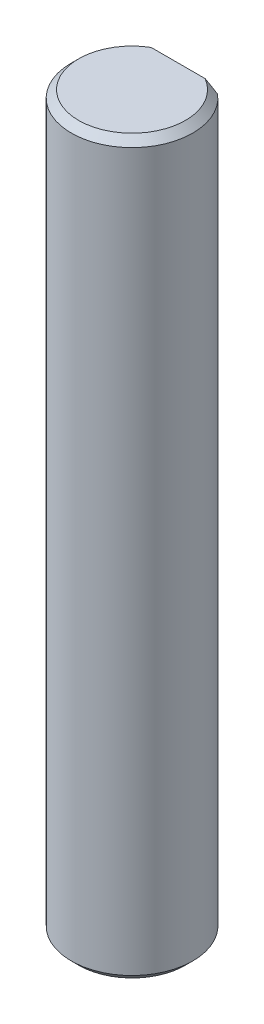
from build123d import *

# Parameters (mm, degrees)
SKETCH1_R           = 4.15
BOSS_EXTRUDE1_DEPTH = 50
CUT_EXTRUDE1_DEPTH  = 16
CHAMFER1_SIZE       = 0.5


with BuildPart() as part:
    # Sketch1 → Boss-Extrude1 (new body)
    with BuildSketch(Plane(origin=(0, 0, 0), x_dir=(1, 0, 0), z_dir=(0, 1, 0))):
        Circle(SKETCH1_R)
    extrude(amount=BOSS_EXTRUDE1_DEPTH)

    # Sketch2 → Cut-Extrude1 (cut)
    with BuildSketch(Plane(origin=(0, 50, 0), x_dir=(1, 0, 0), z_dir=(0, 1, 0))):
        with BuildLine():
            Line((-2.701851217, 3.15), (2.701851217, 3.15))
            ThreePointArc((2.701851217, 3.15), (0, 4.15), (-2.701851217, 3.15))
        make_face()
    cut_extrude1 = extrude(amount=-CUT_EXTRUDE1_DEPTH, mode=Mode.SUBTRACT)

    # Mirror1: Cut-Extrude1 across plane
    add(cut_extrude1.mirror(Plane.ZX.offset(25)), mode=Mode.SUBTRACT)

    # Chamfer1
    chamfer1_edges = [part.edges().sort_by_distance(p)[0] for p in [
        (-1.733467255, 0, 3.770622134),
        (-1.733467255, 50, 3.770622134),
    ]]
    chamfer(chamfer1_edges, length=CHAMFER1_SIZE)


solid = part.part
